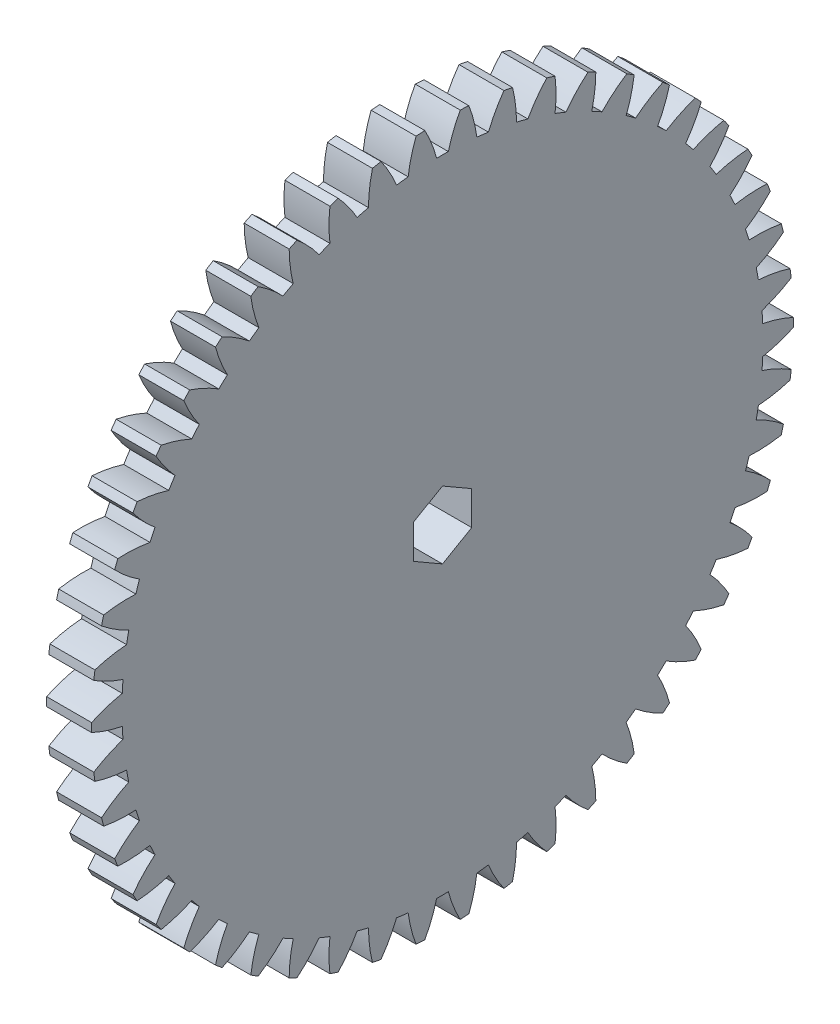
from build123d import *

# Parameters (mm, degrees)
BASPROSKE_W         = 5
BASPROSKE_H         = 39
TOOTHCUT_DEPTH      = 56.380501984
TEETHCUTS_COUNT     = 50
TEETHCUTS_ANGLE     = 352.8
BORE_DEPTH          = 50.0000508
BOSS_EXTRUDE1_DEPTH = 11.2


with BuildPart() as part:
    # BasProSke → Base-Revolve (revolve)
    with BuildSketch(Plane(origin=(0, 0, 0), x_dir=(1, 0, 0), z_dir=(0, 1, 0)), mode=Mode.PRIVATE) as base_revolve_sk:
        with Locations((2.5, 19.5)):
            Rectangle(BASPROSKE_W, BASPROSKE_H)
    revolve(base_revolve_sk.sketch.rotate(Axis((-10, 0, 0), (1, 0, 0)), 180), axis=Axis((-10, 0, 0), (1, 0, 0)))

    # TooCutSke → ToothCut (cut, through all)
    with BuildSketch(Plane(origin=(0, 0, 0), x_dir=(0, 0, -1), z_dir=(1, 0, 0))):
        with BuildLine():
            ThreePointArc((0.649974317, 35.618069984), (0, 35.624), (-0.649974317, 35.618069984))
            ThreePointArc((-0.649974317, 35.618069984), (-1.213667282, 37.336773563), (-1.980135572, 38.975131921))
            ThreePointArc((-1.980135572, 38.975131921), (0, 39.0254), (1.980135572, 38.975131921))
            ThreePointArc((1.980135572, 38.975131921), (1.213667282, 37.336773563), (0.649974317, 35.618069984))
        make_face()
    toothcut = extrude(amount=TOOTHCUT_DEPTH, mode=Mode.SUBTRACT)

    # TeethCuts: ToothCut ×50 about axis
    teethcuts_axis = Axis((-10, 0, 0), (1, 0, 0))
    for i in range(1, TEETHCUTS_COUNT):
        add(toothcut.rotate(teethcuts_axis, i * TEETHCUTS_ANGLE / (TEETHCUTS_COUNT - 1)), mode=Mode.SUBTRACT)

    # BorSke → Bore (cut, symmetric)
    with BuildSketch(Plane(origin=(0, 0, 0), x_dir=(0, 0, -1), z_dir=(1, 0, 0))):
        Polygon((0, -3.75), (3.247595264, -1.875), (3.247595264, 1.875), (0, 3.75), (-3.247595264, 1.875), (-3.247595264, -1.875), align=None)
    extrude(amount=BORE_DEPTH, both=True, mode=Mode.SUBTRACT)

    # Sketch1 → Boss-Extrude1 (add)
    with BuildSketch(Plane.ZY):
        with BuildLine():
            ThreePointArc((0.186825145, -8.9980607), (1.087459567, -7.388027907), (0.875696034, -5.555405697))
            ThreePointArc((0.875696034, -5.555405697), (1.737911579, -5.348741847), (2.556932571, -5.009138831))
            ThreePointArc((2.556932571, -5.009138831), (3.462800583, -6.616232824), (5.137782668, -7.389397083))
            ThreePointArc((5.137782668, -7.389397083), (5.290067274, -7.281152947), (5.440072096, -7.169770958))
            ThreePointArc((5.440072096, -7.169770958), (5.222347117, -5.337847436), (3.973838512, -3.979696405))
            ThreePointArc((3.973838512, -3.979696405), (4.549911578, -3.305704257), (5.012899835, -2.549551185))
            ThreePointArc((5.012899835, -2.549551185), (6.690388599, -3.317261679), (8.499932121, -2.958234937))
            ThreePointArc((8.499932121, -2.958234937), (8.559508648, -2.781152945), (8.615396408, -2.602872401))
            ThreePointArc((8.615396408, -2.602872401), (7.36247557, -1.248790671), (5.554109745, -0.883878352))
            ThreePointArc((5.554109745, -0.883878352), (5.624, 3e-09), (5.554109744, 0.883878357))
            ThreePointArc((5.554109744, 0.883878357), (7.362475569, 1.248790678), (8.615396405, 2.602872409))
            ThreePointArc((8.615396405, 2.602872409), (8.559508645, 2.781152953), (8.499932118, 2.958234945))
            ThreePointArc((8.499932118, 2.958234945), (6.690388596, 3.317261685), (5.012899832, 2.54955119))
            ThreePointArc((5.012899832, 2.54955119), (4.549911575, 3.305704261), (3.973838508, 3.979696409))
            ThreePointArc((3.973838508, 3.979696409), (5.222347112, 5.33784744), (5.44007209, 7.169770963))
            ThreePointArc((5.44007209, 7.169770963), (5.290067267, 7.281152952), (5.137782661, 7.389397088))
            ThreePointArc((5.137782661, 7.389397088), (3.462800577, 6.616232827), (2.556932566, 5.009138833))
            ThreePointArc((2.556932566, 5.009138833), (1.737911574, 5.348741848), (0.875696028, 5.555405698))
            ThreePointArc((0.875696028, 5.555405698), (1.08745956, 7.388027908), (0.186825137, 8.9980607))
            ThreePointArc((0.186825137, 8.9980607), (-4e-09, 9), (-0.186825145, 8.9980607))
            ThreePointArc((-0.186825145, 8.9980607), (-1.087459567, 7.388027907), (-0.875696034, 5.555405697))
            ThreePointArc((-0.875696034, 5.555405697), (-1.737911579, 5.348741847), (-2.556932571, 5.009138831))
            ThreePointArc((-2.556932571, 5.009138831), (-3.462800583, 6.616232824), (-5.137782668, 7.389397083))
            ThreePointArc((-5.137782668, 7.389397083), (-5.290067274, 7.281152947), (-5.440072096, 7.169770958))
            ThreePointArc((-5.440072096, 7.169770958), (-5.222347117, 5.337847436), (-3.973838512, 3.979696405))
            ThreePointArc((-3.973838512, 3.979696405), (-4.549911578, 3.305704257), (-5.012899835, 2.549551185))
            ThreePointArc((-5.012899835, 2.549551185), (-6.690388599, 3.317261679), (-8.499932121, 2.958234937))
            ThreePointArc((-8.499932121, 2.958234937), (-8.559508648, 2.781152945), (-8.615396408, 2.602872401))
            ThreePointArc((-8.615396408, 2.602872401), (-7.36247557, 1.248790671), (-5.554109745, 0.883878352))
            ThreePointArc((-5.554109745, 0.883878352), (-5.624, -3e-09), (-5.554109744, -0.883878357))
            ThreePointArc((-5.554109744, -0.883878357), (-7.362475569, -1.248790678), (-8.615396405, -2.602872409))
            ThreePointArc((-8.615396405, -2.602872409), (-8.559508645, -2.781152953), (-8.499932118, -2.958234945))
            ThreePointArc((-8.499932118, -2.958234945), (-6.690388596, -3.317261685), (-5.012899832, -2.54955119))
            ThreePointArc((-5.012899832, -2.54955119), (-4.549911575, -3.305704261), (-3.973838508, -3.979696409))
            ThreePointArc((-3.973838508, -3.979696409), (-5.222347112, -5.33784744), (-5.44007209, -7.169770963))
            ThreePointArc((-5.44007209, -7.169770963), (-5.290067267, -7.281152952), (-5.137782661, -7.389397088))
            ThreePointArc((-5.137782661, -7.389397088), (-3.462800577, -6.616232827), (-2.556932566, -5.009138833))
            ThreePointArc((-2.556932566, -5.009138833), (-1.737911574, -5.348741848), (-0.875696028, -5.555405698))
            ThreePointArc((-0.875696028, -5.555405698), (-1.08745956, -7.388027908), (-0.186825137, -8.9980607))
            ThreePointArc((-0.186825137, -8.9980607), (4e-09, -9), (0.186825145, -8.9980607))
        make_face()
        Polygon((3.247595264, -1.875), (3.247595264, 1.875), (0, 3.75), (-3.247595264, 1.875), (-3.247595264, -1.875), (0, -3.75), align=None, mode=Mode.SUBTRACT)
    extrude(amount=BOSS_EXTRUDE1_DEPTH)


solid = part.part
